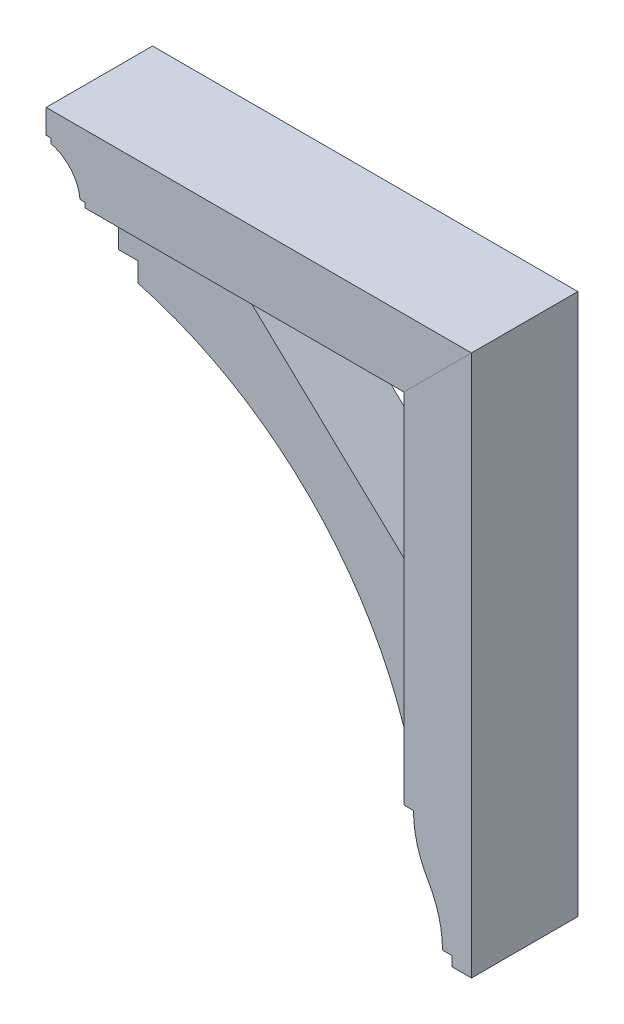
from build123d import *

# Parameters (mm, degrees)
BOSS_EXTRUDE1_DEPTH = 69.85
BOSS_EXTRUDE2_DEPTH = 44.45
BOSS_EXTRUDE3_DEPTH = 69.85


with BuildPart() as part:
    # Sketch1 → Boss-Extrude1 (new body, symmetric)
    with BuildSketch(Plane.XY):
        with BuildLine():
            Line((-229.368776984, 337.185), (-229.368776984, 343.535))
            Line((-229.368776984, 343.535), (-235.718776984, 343.535))
            Line((-235.718776984, 343.535), (-235.718776984, 375.285))
            Line((-235.718776984, 375.285), (323.081223016, 375.285))
            Line((323.081223016, 375.285), (234.181223016, 286.385))
            Line((234.181223016, 286.385), (-184.918776984, 286.385))
            Line((-184.918776984, 286.385), (-184.918776984, 292.735))
            Line((-184.918776984, 292.735), (-191.268776984, 292.735))
            ThreePointArc((-191.268776984, 292.735), (-203.260423906, 321.010016924), (-229.368776984, 337.185))
        make_face()
    extrude(amount=BOSS_EXTRUDE1_DEPTH, both=True)


with BuildPart() as body_2:
    # Sketch1_3 → Boss-Extrude2 (new body, symmetric)
    with BuildSketch(Plane.XY):
        with BuildLine():
            Line((234.181223016, 48.22444), (-17.720736984, 286.385))
            Line((-17.720736984, 286.385), (-165.868776984, 286.385))
            Line((-165.868776984, 286.385), (-165.868776984, 235.585))
            Line((-165.868776984, 235.585), (-140.468776984, 235.585))
            Line((-140.468776984, 235.585), (-140.468776984, 210.185))
            ThreePointArc((-140.468776984, 210.185), (75.677544074, 89.001781889), (208.781223016, -120.015))
            Line((208.781223016, -120.015), (234.181223016, -120.015))
            Line((234.181223016, -120.015), (234.181223016, 48.22444))
        make_face()
    extrude(amount=BOSS_EXTRUDE2_DEPTH, both=True)


with BuildPart() as body_3:
    # Sketch1_4 → Boss-Extrude3 (new body, symmetric)
    with BuildSketch(Plane.XY):
        with BuildLine():
            ThreePointArc((265.948759904, -253.429301925), (251.733596793, -219.748894963), (246.881223016, -183.515))
            Line((246.881223016, -183.515), (234.181223016, -183.515))
            Line((234.181223016, -183.515), (234.181223016, 286.385))
            Line((234.181223016, 286.385), (323.081223016, 375.285))
            Line((323.081223016, 375.285), (323.081223016, -335.915))
            Line((323.081223016, -335.915), (297.681223016, -335.915))
            Line((297.681223016, -335.915), (297.681223016, -323.215))
            Line((297.681223016, -323.215), (284.981223016, -323.215))
            ThreePointArc((284.981223016, -323.215), (280.137774937, -287.047755469), (265.948759904, -253.429301925))
        make_face()
    extrude(amount=BOSS_EXTRUDE3_DEPTH, both=True)


solid = Compound([part.part, body_2.part, body_3.part])
